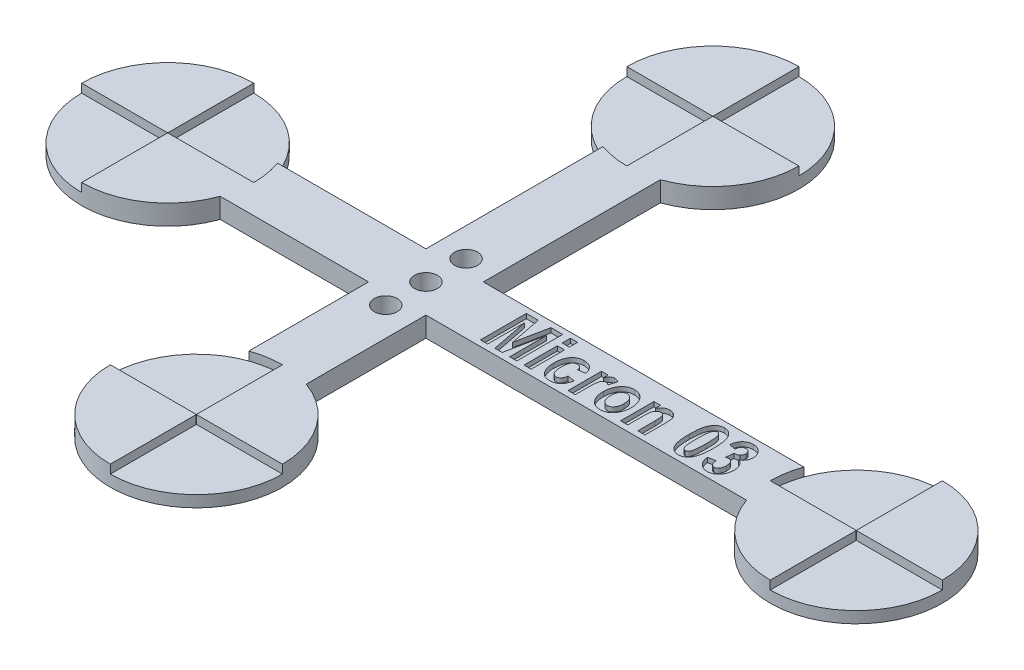
from build123d import *

# Parameters (mm, degrees)
BOSS_EXTRUDE1_DEPTH = 3.5
CUT_EXTRUDE1_DEPTH  = 1.5
SKETCH3_W           = 1.246753247
SKETCH3_H           = 1.454545455
SKETCH3_H_2         = 5.818181818
CUT_EXTRUDE2_DEPTH  = 0.8
SKETCH4_R           = 2
CUT_EXTRUDE3_DEPTH  = 4.5


with BuildPart() as part:
    # Sketch1 → Boss-Extrude1 (new body)
    with BuildSketch(Plane(origin=(0, 0, 0), x_dir=(1, 0, 0), z_dir=(0, 1, 0))):
        with BuildLine():
            Line((40, 35.857864376), (40, 5))
            Line((40, 5), (14.142135624, 5))
            ThreePointArc((14.142135624, 5), (-15, 0), (14.142135624, -5))
            Line((14.142135624, -5), (40, -5))
            Line((40, -5), (40, -25.857864376))
            ThreePointArc((40, -25.857864376), (45, -55), (50, -25.857864376))
            Line((50, -25.857864376), (50, -5))
            Line((50, -5), (105.857864376, -5))
            ThreePointArc((105.857864376, -5), (135, 0), (105.857864376, 5))
            Line((105.857864376, 5), (50, 5))
            Line((50, 5), (50, 35.857864376))
            ThreePointArc((50, 35.857864376), (45, 65), (40, 35.857864376))
        make_face()
    extrude(amount=BOSS_EXTRUDE1_DEPTH)

    # Sketch2 → Cut-Extrude1 (cut)
    with BuildSketch(Plane(origin=(0, 3.5, 0), x_dir=(1, 0, 0), z_dir=(0, 1, 0))):
        with BuildLine():
            Line((-15, 0), (-0.05, 0))
            ThreePointArc((-0.05, 0), (-0.035355339, 0.035355339), (0, 0.05))
            Line((0, 0.05), (0, 15))
            ThreePointArc((0, 15), (10.606601718, 10.606601718), (15, 0))
            Line((15, 0), (0.05, 0))
            ThreePointArc((0.05, 0), (0.035355339, -0.035355339), (0, -0.05))
            Line((0, -0.05), (0, -15))
            ThreePointArc((0, -15), (-10.606601718, -10.606601718), (-15, 0))
        make_face()
        with BuildLine():
            Line((45, 65), (45, 50.05))
            ThreePointArc((45, 50.05), (44.964644661, 50.035355339), (44.95, 50))
            Line((44.95, 50), (30, 50))
            ThreePointArc((30, 50), (34.393398282, 39.393398282), (45, 35))
            Line((45, 35), (45, 49.95))
            ThreePointArc((45, 49.95), (45.035355339, 49.964644661), (45.05, 50))
            Line((45.05, 50), (60, 50))
            ThreePointArc((60, 50), (55.606601718, 60.606601718), (45, 65))
        make_face()
        with BuildLine():
            Line((120, 15), (120, 0.05))
            ThreePointArc((120, 0.05), (120.035355339, 0.035355339), (120.05, 0))
            Line((120.05, 0), (135, 0))
            ThreePointArc((135, 0), (130.606601718, -10.606601718), (120, -15))
            Line((120, -15), (120, -0.05))
            ThreePointArc((120, -0.05), (119.964644661, -0.035355339), (119.95, 0))
            Line((119.95, 0), (105, 0))
            ThreePointArc((105, 0), (109.393398282, 10.606601718), (120, 15))
        make_face()
        with BuildLine():
            Line((30, -40), (44.95, -40))
            ThreePointArc((44.95, -40), (44.964644661, -40.035355339), (45, -40.05))
            Line((45, -40.05), (45, -55))
            ThreePointArc((45, -55), (55.606601718, -50.606601718), (60, -40))
            Line((60, -40), (45.05, -40))
            ThreePointArc((45.05, -40), (45.035355339, -39.964644661), (45, -39.95))
            Line((45, -39.95), (45, -25))
            ThreePointArc((45, -25), (34.393398282, -29.393398282), (30, -40))
        make_face()
    extrude(amount=-CUT_EXTRUDE1_DEPTH, mode=Mode.SUBTRACT)

    # Sketch3 → Cut-Extrude2 (cut)
    with BuildSketch(Plane(origin=(0, 3.5, 0), x_dir=(1, 0, 0), z_dir=(0, 1, 0))):
        Polygon((58.50036076, -4), (58.50036076, 4), (60.563672448, 4), (61.669191928, -1.561688312), (62.795815305, 4), (64.838023097, 4), (64.838023097, -4), (63.59126985, -4), (63.59126985, 2.400974026), (62.290945175, -4), (61.023088032, -4), (59.747114006, 2.400974026), (59.747114006, -4), align=None)
        with Locations((66.708152968, 3.376623377)):
            Rectangle(SKETCH3_W, SKETCH3_H)
        with Locations((66.708152968, -1.090909091)):
            Rectangle(SKETCH3_W, SKETCH3_H_2)
        with BuildLine():
            Line((72.734126993, 0.155844156), (71.487373747, -0.051948052))
            add(Edge.make_bspline(
                [(71.487373747, -0.051948052), (71.475238631, 0.013492139), (71.452160271, 0.137945199), (71.389179941, 0.307989308), (71.312160634, 0.454611766), (71.213055442, 0.573886506), (71.095416345, 0.667213464), (70.958609537, 0.733166985), (70.803936467, 0.772456922), (70.694860886, 0.776912369), (70.638347773, 0.779220779)],
                knots=[0, 0, 0, 0, 0.000199325, 0.000379073, 0.0005418, 0.000693948, 0.000840745, 0.000988855, 0.001146348, 0.001315678, 0.001315678, 0.001315678, 0.001315678], degree=3))
            add(Edge.make_bspline(
                [(70.638347773, 0.779220779), (70.600905429, 0.778062939), (70.527122523, 0.775781331), (70.420010496, 0.755102855), (70.317553938, 0.725549098), (70.222958212, 0.677663569), (70.130758823, 0.622007918), (70.046957124, 0.549315551), (69.968136169, 0.465515202), (69.894709448, 0.369037743), (69.827095322, 0.257785931), (69.770603047, 0.128257783), (69.725083376, -0.018687378), (69.68335517, -0.181979253), (69.653655963, -0.363419746), (69.633180941, -0.562384664), (69.620101663, -0.77850796), (69.618220871, -0.928551854), (69.617243876, -1.006493506)],
                knots=[0, 0, 0, 0, 0.000112201, 0.0002211, 0.00032637, 0.000430923, 0.000538128, 0.000648708, 0.000762403, 0.000882861, 0.001011764, 0.001152033, 0.001305535, 0.001472868, 0.001657284, 0.001856457, 0.002072757, 0.002306574, 0.002306574, 0.002306574, 0.002306574], degree=3))
            add(Edge.make_bspline(
                [(69.617243876, -1.006493506), (69.618261217, -1.092546265), (69.620213954, -1.257720471), (69.632711779, -1.496116795), (69.65538517, -1.714396148), (69.685469478, -1.914085761), (69.725675307, -2.093641007), (69.774055334, -2.254680712), (69.831596703, -2.395907747), (69.899086485, -2.518208897), (69.974173657, -2.623094471), (70.056196277, -2.712538943), (70.142228328, -2.791034021), (70.2374127, -2.851962864), (70.336627186, -2.901864568), (70.442857496, -2.935934853), (70.55464497, -2.95784839), (70.631749283, -2.959966029), (70.670815305, -2.961038961)],
                knots=[0, 0, 0, 0, 0.000258163, 0.000495531, 0.000715862, 0.000916302, 0.00110101, 0.001267389, 0.001420236, 0.001557572, 0.001685521, 0.001806187, 0.001921184, 0.002033748, 0.002144102, 0.002253448, 0.002367432, 0.002484495, 0.002484495, 0.002484495, 0.002484495], degree=3))
            add(Edge.make_bspline(
                [(70.670815305, -2.961038961), (70.72855094, -2.958115137), (70.840148837, -2.952463643), (70.998917272, -2.902884688), (71.141871425, -2.82385793), (71.244914469, -2.730611667), (71.318466989, -2.639969699), (71.370108431, -2.557981246), (71.418545215, -2.464077917), (71.462084604, -2.358060987), (71.501266248, -2.240396767), (71.534349316, -2.110465037), (71.565645908, -1.968673701), (71.582502685, -1.869672225), (71.59126985, -1.818181818)],
                knots=[0, 0, 0, 0, 0.000172842, 0.000334088, 0.000493972, 0.000659525, 0.000747247, 0.000843616, 0.000949622, 0.001063883, 0.001187088, 0.001321358, 0.001465921, 0.001622591, 0.001622591, 0.001622591, 0.001622591], degree=3))
            Line((71.59126985, -1.818181818), (72.838023097, -2.025974026))
            add(Edge.make_bspline(
                [(72.838023097, -2.025974026), (72.821015846, -2.110033143), (72.787894315, -2.273737832), (72.725282574, -2.51019173), (72.648292222, -2.729306841), (72.562922764, -2.933353422), (72.465367894, -3.120817392), (72.35648555, -3.292169834), (72.236010198, -3.447294215), (72.103969601, -3.586117196), (71.960430352, -3.708703947), (71.805564143, -3.814231607), (71.640086257, -3.904896068), (71.462835354, -3.977226655), (71.274845438, -4.034537616), (71.075882267, -4.074640125), (70.865713047, -4.099528833), (70.721752457, -4.102417816), (70.648088032, -4.103896104)],
                knots=[0, 0, 0, 0, 0.000257263, 0.000501018, 0.000733076, 0.000953485, 0.001164055, 0.001366255, 0.001561742, 0.001752349, 0.001940051, 0.002126916, 0.002313611, 0.002505046, 0.002700189, 0.002902356, 0.003113183, 0.003334111, 0.003334111, 0.003334111, 0.003334111], degree=3))
            add(Edge.make_bspline(
                [(70.648088032, -4.103896104), (70.554819841, -4.101887492), (70.37321271, -4.097976423), (70.110471697, -4.053593587), (69.864673186, -3.987367001), (69.639207309, -3.888476021), (69.431834059, -3.764176577), (69.243759839, -3.611361294), (69.073517705, -3.431602628), (68.925921273, -3.224317401), (68.795814013, -2.999463478), (68.681997355, -2.762165056), (68.585965745, -2.513438303), (68.506034653, -2.254410985), (68.446476255, -1.98270864), (68.403410095, -1.700737492), (68.374039392, -1.407542533), (68.371686907, -1.208406699), (68.37049063, -1.107142857)],
                knots=[0, 0, 0, 0, 0.000279523, 0.000544272, 0.000797144, 0.001041429, 0.001280302, 0.001520398, 0.001766145, 0.002020725, 0.002281892, 0.002544739, 0.002809429, 0.003081077, 0.00335717, 0.003643018, 0.003936526, 0.004240206, 0.004240206, 0.004240206, 0.004240206], degree=3))
            add(Edge.make_bspline(
                [(68.37049063, -1.107142857), (68.372239743, -0.987488549), (68.375640625, -0.75483916), (68.405336818, -0.417027711), (68.452726945, -0.100401237), (68.522926455, 0.193547978), (68.609847208, 0.466113039), (68.716501303, 0.716580192), (68.846096582, 0.943069469), (68.991820845, 1.149170928), (69.156114523, 1.330213011), (69.331961705, 1.489088097), (69.520060194, 1.623763244), (69.721234776, 1.733258723), (69.935011157, 1.818073271), (70.160732658, 1.877319248), (70.397782122, 1.916873853), (70.560259998, 1.920318934), (70.643217902, 1.922077922)],
                knots=[0, 0, 0, 0, 0.000358898, 0.000697823, 0.001016501, 0.00131851, 0.001603435, 0.001873935, 0.002133483, 0.002384849, 0.002629678, 0.002865336, 0.003094623, 0.003322001, 0.003550805, 0.003782743, 0.004021075, 0.004269712, 0.004269712, 0.004269712, 0.004269712], degree=3))
            add(Edge.make_bspline(
                [(70.643217902, 1.922077922), (70.71035858, 1.920846466), (70.841687336, 1.918437708), (71.034520622, 1.899106266), (71.217142954, 1.864581364), (71.391368457, 1.819675788), (71.554972261, 1.759740953), (71.709026878, 1.685791916), (71.853826329, 1.599814288), (71.98980103, 1.500415487), (72.115185036, 1.385394066), (72.233134509, 1.256930605), (72.340019014, 1.110862201), (72.439342218, 0.950708523), (72.526615855, 0.773374249), (72.606095879, 0.582082787), (72.676087051, 0.374743093), (72.714406275, 0.230221286), (72.734126993, 0.155844156)],
                knots=[0, 0, 0, 0, 0.000201403, 0.00039395, 0.000580532, 0.000758512, 0.000933129, 0.001102311, 0.00127047, 0.001437685, 0.001606618, 0.001780137, 0.00196001, 0.002148783, 0.002344802, 0.00255222, 0.002769885, 0.003000685, 0.003000685, 0.003000685, 0.003000685], degree=3))
        make_face()
        with BuildLine():
            Line((75.019841279, -4), (73.773088032, -4))
            Line((73.773088032, -4), (73.773088032, 1.818181818))
            Line((73.773088032, 1.818181818), (74.915945175, 1.818181818))
            Line((74.915945175, 1.818181818), (74.915945175, 0.991883117))
            add(Edge.make_bspline(
                [(74.915945175, 0.991883117), (74.940159399, 1.037952881), (74.986797897, 1.126686869), (75.05617644, 1.253336089), (75.123683954, 1.367923953), (75.192594719, 1.467096929), (75.254997633, 1.556811947), (75.319023898, 1.631359029), (75.379881779, 1.694731582), (75.457465413, 1.762170073), (75.560087337, 1.826053482), (75.691232303, 1.882473547), (75.832643067, 1.915363311), (75.929848968, 1.919815142), (75.979256863, 1.922077922)],
                knots=[0, 0, 0, 0, 0.000156131, 0.000300721, 0.000433243, 0.000554812, 0.000662946, 0.000760848, 0.000849244, 0.000926367, 0.001068679, 0.001209792, 0.001353128, 0.001501291, 0.001501291, 0.001501291, 0.001501291], degree=3))
            add(Edge.make_bspline(
                [(75.979256863, 1.922077922), (76.049468143, 1.91886318), (76.189930484, 1.912431875), (76.396264458, 1.852623193), (76.598585759, 1.762131289), (76.72239596, 1.675863479), (76.786075045, 1.631493506)],
                knots=[0, 0, 0, 0, 0.000210176, 0.00042047, 0.000639866, 0.000872208, 0.000872208, 0.000872208, 0.000872208], degree=3))
            Line((76.786075045, 1.631493506), (76.391594526, 0.319805195))
            add(Edge.make_bspline(
                [(76.391594526, 0.319805195), (76.343457298, 0.358255441), (76.252471756, 0.430931343), (76.106176233, 0.509110372), (75.96429064, 0.560954838), (75.869258342, 0.568020125), (75.823412708, 0.571428571)],
                knots=[0, 0, 0, 0, 0.000184416, 0.00034857, 0.000495904, 0.00063323, 0.00063323, 0.00063323, 0.00063323], degree=3))
            add(Edge.make_bspline(
                [(75.823412708, 0.571428571), (75.782505012, 0.569577552), (75.701066257, 0.565892554), (75.584319511, 0.525699903), (75.474380215, 0.46484784), (75.373247856, 0.375884101), (75.28120342, 0.255501948), (75.208770468, 0.094601523), (75.146148418, -0.102439271), (75.107437305, -0.295455124), (75.083085691, -0.477538767), (75.06505598, -0.645297865), (75.050951083, -0.839680763), (75.040281294, -1.060551746), (75.030100881, -1.307830134), (75.023930168, -1.582222395), (75.021131213, -1.883652001), (75.020282911, -2.093614232), (75.019841279, -2.202922078)],
                knots=[0, 0, 0, 0, 0.000122282, 0.000243439, 0.00036627, 0.000497452, 0.000644536, 0.000817347, 0.001023727, 0.001264102, 0.001406673, 0.001574831, 0.001770184, 0.001991255, 0.002238201, 0.002512628, 0.002814594, 0.00314252, 0.00314252, 0.00314252, 0.00314252], degree=3))
            Line((75.019841279, -2.202922078), (75.019841279, -4))
        make_face()
        with BuildLine():
            add(Edge.make_bspline(
                [(76.993867253, -1.00974026), (76.99773938, -0.871492577), (77.005358765, -0.599455473), (77.07087566, -0.202105645), (77.173904845, 0.177168447), (77.298261932, 0.475142281), (77.414852128, 0.700213025), (77.508933594, 0.858166819), (77.610211845, 1.0047968), (77.716400181, 1.140905493), (77.830224235, 1.265802708), (77.948905998, 1.380456268), (78.075551332, 1.483975824), (78.251872281, 1.606243165), (78.48640792, 1.734106031), (78.786697572, 1.843482079), (79.103960535, 1.910979968), (79.321452502, 1.918333961), (79.432178941, 1.922077922)],
                knots=[0, 0, 0, 0, 0.000414499, 0.00081563, 0.001204757, 0.001591247, 0.00178148, 0.00196495, 0.002142367, 0.002315787, 0.002482426, 0.002648908, 0.002810415, 0.002972534, 0.003292157, 0.00360852, 0.00392849, 0.004260331, 0.004260331, 0.004260331, 0.004260331], degree=3))
            add(Edge.make_bspline(
                [(79.432178941, 1.922077922), (79.524844362, 1.919080026), (79.706214487, 1.913212371), (79.970819979, 1.872921067), (80.219608224, 1.802229151), (80.453953528, 1.705294578), (80.670723745, 1.576365199), (80.874437856, 1.423442467), (81.059923504, 1.239208288), (81.228428557, 1.030627633), (81.37997441, 0.803981072), (81.513296238, 0.565748818), (81.625008798, 0.317712454), (81.719657136, 0.061815795), (81.787549524, -0.205805812), (81.840332848, -0.481537671), (81.871889339, -0.767122546), (81.87526987, -0.960420315), (81.876984136, -1.058441558)],
                knots=[0, 0, 0, 0, 0.000277982, 0.000544082, 0.000800519, 0.001052268, 0.001302568, 0.001555169, 0.001814604, 0.002084622, 0.002358372, 0.002631625, 0.002902613, 0.00317376, 0.003448993, 0.003729814, 0.004015574, 0.004309567, 0.004309567, 0.004309567, 0.004309567], degree=3))
            add(Edge.make_bspline(
                [(81.876984136, -1.058441558), (81.876227692, -1.131529258), (81.874729677, -1.276267575), (81.857345801, -1.490737935), (81.832372892, -1.700083082), (81.794451847, -1.904353031), (81.74632035, -2.102762528), (81.686787225, -2.295895078), (81.619804227, -2.484139081), (81.53955722, -2.665021822), (81.453170655, -2.838694854), (81.356567034, -3.000287959), (81.256676902, -3.152976813), (81.14667086, -3.291813358), (81.033747016, -3.423233057), (80.911462009, -3.541439921), (80.783056626, -3.649149424), (80.604551972, -3.775655653), (80.369934842, -3.906802618), (80.071483883, -4.020332864), (79.759616253, -4.091116904), (79.546182896, -4.0996153), (79.438672448, -4.103896104)],
                knots=[0, 0, 0, 0, 0.00021921, 0.00043411, 0.00064513, 0.000851458, 0.001056987, 0.001257262, 0.001457537, 0.001655994, 0.001850563, 0.002039049, 0.002220497, 0.002397475, 0.002570043, 0.002739947, 0.002907061, 0.003072374, 0.003395769, 0.003710226, 0.004027699, 0.00434993, 0.00434993, 0.00434993, 0.00434993], degree=3))
            add(Edge.make_bspline(
                [(79.438672448, -4.103896104), (79.352502729, -4.101341217), (79.183124459, -4.096319241), (78.934716636, -4.058456248), (78.698054839, -3.99479852), (78.472549003, -3.90676201), (78.258016744, -3.793542556), (78.054181778, -3.655526311), (77.864029071, -3.488983811), (77.683779026, -3.302138577), (77.520670531, -3.090331966), (77.380150134, -2.855461331), (77.258457363, -2.600481865), (77.162310721, -2.322961565), (77.085543251, -2.024985427), (77.033233234, -1.70496049), (77.000302919, -1.364326972), (76.996049016, -1.12994916), (76.993867253, -1.00974026)],
                knots=[0, 0, 0, 0, 0.000258443, 0.000508006, 0.000751761, 0.000992327, 0.001232686, 0.001478079, 0.001728994, 0.001989631, 0.002255885, 0.002529003, 0.002809298, 0.003101956, 0.003408675, 0.003731336, 0.004073787, 0.004434356, 0.004434356, 0.004434356, 0.004434356], degree=3))
        make_face()
        with BuildLine():
            add(Edge.make_bspline(
                [(78.2406205, -1.090909091), (78.241193573, -1.161301131), (78.242306492, -1.298003716), (78.261234707, -1.496347271), (78.288602558, -1.681695553), (78.324236438, -1.854514739), (78.376162408, -2.012893615), (78.434745234, -2.159458772), (78.506897923, -2.292206203), (78.589461187, -2.410648066), (78.680939517, -2.51464094), (78.776964817, -2.605361366), (78.875632321, -2.685555047), (78.982414792, -2.746314388), (79.091993225, -2.7960892), (79.205812587, -2.83181335), (79.324708332, -2.854023891), (79.405564639, -2.856089635), (79.446789331, -2.857142857)],
                knots=[0, 0, 0, 0, 0.000211095, 0.000409951, 0.000597062, 0.000773144, 0.000938458, 0.001096426, 0.001246068, 0.00139063, 0.001528684, 0.001660738, 0.001786746, 0.001908974, 0.002028146, 0.002147262, 0.002266036, 0.002389583, 0.002389583, 0.002389583, 0.002389583], degree=3))
            add(Edge.make_bspline(
                [(79.446789331, -2.857142857), (79.486930477, -2.856062286), (79.566168615, -2.853929251), (79.682924616, -2.831796204), (79.794636913, -2.796265769), (79.902095046, -2.746661195), (80.004819397, -2.682536946), (80.103605063, -2.604942025), (80.196824143, -2.512150646), (80.285902055, -2.407554507), (80.367452538, -2.288190002), (80.439332996, -2.15529938), (80.496230932, -2.007207398), (80.548090785, -1.84851973), (80.583928744, -1.674677795), (80.611733592, -1.488309881), (80.627963108, -1.288165559), (80.629460002, -1.150461681), (80.630230889, -1.079545455)],
                knots=[0, 0, 0, 0, 0.000120305, 0.000237481, 0.00035505, 0.000471266, 0.000591549, 0.000717557, 0.000847275, 0.000985501, 0.00112914, 0.00128021, 0.001437568, 0.001604429, 0.001780511, 0.001969228, 0.002169562, 0.00238228, 0.00238228, 0.00238228, 0.00238228], degree=3))
            add(Edge.make_bspline(
                [(80.630230889, -1.079545455), (80.629657673, -1.010234819), (80.628544962, -0.875690947), (80.609642621, -0.680588811), (80.582133444, -0.497953131), (80.546465486, -0.327351399), (80.49521573, -0.170068224), (80.433692654, -0.025632812), (80.362554163, 0.1072581), (80.279265313, 0.225728002), (80.188791642, 0.330494971), (80.093903874, 0.422586459), (79.99490702, 0.50126615), (79.890651683, 0.564846212), (79.782053107, 0.614109415), (79.669460084, 0.65026489), (79.551531628, 0.672061169), (79.471231571, 0.67422738), (79.430555565, 0.675324675)],
                knots=[0, 0, 0, 0, 0.000207849, 0.000403471, 0.000587372, 0.000761868, 0.000925636, 0.001082735, 0.001232376, 0.001376939, 0.001516219, 0.001647099, 0.001773107, 0.001894774, 0.002012466, 0.002130035, 0.002248808, 0.002370734, 0.002370734, 0.002370734, 0.002370734], degree=3))
            add(Edge.make_bspline(
                [(79.430555565, 0.675324675), (79.390416835, 0.674238638), (79.311183466, 0.672094813), (79.194392368, 0.650041164), (79.082343389, 0.614060182), (78.973968514, 0.565297339), (78.870848855, 0.500737434), (78.772125734, 0.422584114), (78.677081903, 0.331022603), (78.588667404, 0.225050714), (78.504100416, 0.107532851), (78.436606876, -0.027537366), (78.372844625, -0.171655992), (78.32568136, -0.331268167), (78.285792867, -0.502358852), (78.261951191, -0.687847561), (78.242143614, -0.884859588), (78.241136929, -1.021045607), (78.2406205, -1.090909091)],
                knots=[0, 0, 0, 0, 0.000120305, 0.000237481, 0.00035505, 0.000472742, 0.000593025, 0.000719033, 0.000849914, 0.000988139, 0.001132702, 0.001283011, 0.00144011, 0.001604937, 0.00178137, 0.001966642, 0.002165497, 0.002374969, 0.002374969, 0.002374969, 0.002374969], degree=3))
        make_face(mode=Mode.SUBTRACT)
        with BuildLine():
            Line((87.175685435, -4), (85.928932188, -4))
            Line((85.928932188, -4), (85.928932188, -1.025974026))
            add(Edge.make_bspline(
                [(85.928932188, -1.025974026), (85.92854282, -0.954543529), (85.927799442, -0.818169062), (85.924356954, -0.622819841), (85.920247564, -0.445806445), (85.911867341, -0.287253276), (85.902241106, -0.147618119), (85.891650159, -0.026736408), (85.87710847, 0.075056785), (85.856368171, 0.184335425), (85.821004006, 0.301543782), (85.764596313, 0.426141455), (85.692774231, 0.534382367), (85.604019629, 0.62160385), (85.506619056, 0.69206755), (85.401915582, 0.743240838), (85.289966246, 0.77397023), (85.213215912, 0.777447079), (85.174062058, 0.779220779)],
                knots=[0, 0, 0, 0, 0.000214292, 0.000409124, 0.000586139, 0.000745437, 0.000885387, 0.001006053, 0.001109364, 0.001193733, 0.001339584, 0.001475415, 0.001602837, 0.00172681, 0.001846644, 0.001962086, 0.002074709, 0.002191998, 0.002191998, 0.002191998, 0.002191998], degree=3))
            add(Edge.make_bspline(
                [(85.174062058, 0.779220779), (85.123447016, 0.776869331), (85.023371597, 0.772220076), (84.878191919, 0.730407315), (84.739286208, 0.667322233), (84.612395844, 0.575023409), (84.495650377, 0.46328544), (84.398737064, 0.328262501), (84.317469986, 0.175298829), (84.268630692, 0.030618942), (84.236032455, -0.101357957), (84.218310317, -0.222713773), (84.199402097, -0.363228665), (84.188161741, -0.524290952), (84.175994029, -0.704955422), (84.168471275, -0.905793407), (84.163505023, -1.126597226), (84.162974738, -1.280299629), (84.162698422, -1.36038961)],
                knots=[0, 0, 0, 0, 0.000151532, 0.000299606, 0.000449951, 0.00060715, 0.000767873, 0.000932819, 0.001103467, 0.001285727, 0.00138928, 0.001510979, 0.001653337, 0.001814575, 0.001995128, 0.00219659, 0.002417423, 0.002657688, 0.002657688, 0.002657688, 0.002657688], degree=3))
            Line((84.162698422, -1.36038961), (84.162698422, -4))
            Line((84.162698422, -4), (82.915945175, -4))
            Line((82.915945175, -4), (82.915945175, 1.818181818))
            Line((82.915945175, 1.818181818), (84.058802318, 1.818181818))
            Line((84.058802318, 1.818181818), (84.058802318, 0.965909091))
            add(Edge.make_bspline(
                [(84.058802318, 0.965909091), (84.109710936, 1.041759386), (84.208544913, 1.189015129), (84.378208436, 1.383777654), (84.556148861, 1.549983921), (84.743871586, 1.687067674), (84.943914365, 1.791672469), (85.153616398, 1.866743358), (85.373756253, 1.914536504), (85.524465529, 1.919537791), (85.60101011, 1.922077922)],
                knots=[0, 0, 0, 0, 0.000273831, 0.000531616, 0.00077285, 0.001003084, 0.001226733, 0.001447536, 0.001669767, 0.001899129, 0.001899129, 0.001899129, 0.001899129], degree=3))
            add(Edge.make_bspline(
                [(85.60101011, 1.922077922), (85.688429859, 1.918919658), (85.857463892, 1.912812868), (86.100755155, 1.857826735), (86.32221213, 1.766788484), (86.519497148, 1.639484009), (86.693501252, 1.488180451), (86.837925118, 1.311212589), (86.955005756, 1.115344188), (87.024073318, 0.933951844), (87.069245622, 0.777526046), (87.097815568, 0.646198938), (87.122467785, 0.502145243), (87.140849457, 0.345447453), (87.157608055, 0.176651439), (87.168642166, -0.004744055), (87.17517168, -0.198542646), (87.175511007, -0.332245522), (87.175685435, -0.400974026)],
                knots=[0, 0, 0, 0, 0.000261973, 0.000506549, 0.000743812, 0.00097664, 0.00120785, 0.001432751, 0.0016591, 0.001889414, 0.002012726, 0.002147427, 0.002292345, 0.002451013, 0.002620623, 0.002801175, 0.002996089, 0.003202264, 0.003202264, 0.003202264, 0.003202264], degree=3))
            Line((87.175685435, -0.400974026), (87.175685435, -4))
        make_face()
        with BuildLine():
            add(Edge.make_bspline(
                [(93.042568552, 4), (93.120143484, 3.997148674), (93.273215628, 3.991522391), (93.496552113, 3.948267667), (93.709167709, 3.877994443), (93.909593475, 3.778303449), (94.097951861, 3.649902676), (94.274716094, 3.493575316), (94.44002471, 3.309388361), (94.594940829, 3.095688722), (94.734153575, 2.845756266), (94.853050654, 2.555093261), (94.952904602, 2.222696136), (95.034271056, 1.848605187), (95.098816614, 1.432288922), (95.142527697, 0.973709188), (95.170357365, 0.473287901), (95.173862882, 0.125581293), (95.175685435, -0.055194805)],
                knots=[0, 0, 0, 0, 0.000232602, 0.000458974, 0.000679718, 0.0009026, 0.001128179, 0.00136168, 0.001608802, 0.001869231, 0.002151946, 0.002464883, 0.002809456, 0.003191901, 0.003612528, 0.004072572, 0.004573333, 0.005115628, 0.005115628, 0.005115628, 0.005115628], degree=3))
            add(Edge.make_bspline(
                [(95.175685435, -0.055194805), (95.173858892, -0.235429027), (95.170346113, -0.582052681), (95.14257855, -1.080864069), (95.098621978, -1.538317484), (95.034600767, -1.953666632), (94.952257764, -2.327486698), (94.853811541, -2.659813141), (94.733670888, -2.949980575), (94.595090938, -3.199694145), (94.439887399, -3.412685451), (94.276378827, -3.597979093), (94.099525864, -3.753792128), (93.911527253, -3.881710441), (93.71208139, -3.98233668), (93.500748445, -4.05159659), (93.278700656, -4.095734493), (93.126655602, -4.101138343), (93.049062058, -4.103896104)],
                knots=[0, 0, 0, 0, 0.000540672, 0.001039812, 0.00149824, 0.001918867, 0.002299728, 0.002645854, 0.002957293, 0.003240007, 0.003500437, 0.003746473, 0.003979974, 0.004205554, 0.004426982, 0.004647726, 0.004870909, 0.005103511, 0.005103511, 0.005103511, 0.005103511], degree=3))
            add(Edge.make_bspline(
                [(93.049062058, -4.103896104), (92.971520172, -4.100862637), (92.818612265, -4.094880825), (92.59489671, -4.054282938), (92.382435066, -3.983452229), (92.182511086, -3.883672907), (91.993665393, -3.757214281), (91.816991446, -3.602360262), (91.651459776, -3.419950023), (91.525616278, -3.246353686), (91.430990718, -3.092878847), (91.364980322, -2.964508803), (91.303455869, -2.825479381), (91.244235797, -2.676576112), (91.19349064, -2.514885831), (91.144536647, -2.343474895), (91.100591604, -2.160968409), (91.062673394, -1.967931987), (91.02559404, -1.76477297), (90.998032431, -1.550003327), (90.97076078, -1.325090023), (90.952664467, -1.088321983), (90.93572137, -0.841612758), (90.925283351, -0.583390093), (90.915909942, -0.315001944), (90.915933294, -0.132043959), (90.915945175, -0.038961039)],
                knots=[0, 0, 0, 0, 0.000232602, 0.000458677, 0.000679421, 0.000902303, 0.001126975, 0.001359407, 0.001605326, 0.001864441, 0.002001422, 0.002145912, 0.00229706, 0.002457438, 0.002626339, 0.002805176, 0.002992203, 0.003189274, 0.003395315, 0.003611584, 0.003838724, 0.004074918, 0.004323825, 0.00458057, 0.004850172, 0.005129398, 0.005129398, 0.005129398, 0.005129398], degree=3))
            add(Edge.make_bspline(
                [(90.915945175, -0.038961039), (90.917766425, 0.140733062), (90.92126861, 0.486277146), (90.949096706, 0.983455445), (90.992786068, 1.438795514), (91.057455354, 1.852398974), (91.139031184, 2.224773358), (91.238156972, 2.556355193), (91.357927524, 2.84609395), (91.496547236, 3.095795814), (91.651741372, 3.308789888), (91.815252237, 3.494082856), (91.992104631, 3.649896058), (92.180103387, 3.777814329), (92.379549212, 3.878440579), (92.590882167, 3.947700486), (92.812929954, 3.99183839), (92.964975007, 3.997242239), (93.042568552, 4)],
                knots=[0, 0, 0, 0, 0.000539049, 0.001036568, 0.001493381, 0.0019108, 0.002291661, 0.002636234, 0.002947673, 0.003230387, 0.003490817, 0.003736853, 0.003970355, 0.004195934, 0.004417363, 0.004638106, 0.004861289, 0.005093891, 0.005093891, 0.005093891, 0.005093891], degree=3))
        make_face()
        with BuildLine():
            add(Edge.make_bspline(
                [(93.045815305, 2.753246753), (93.016983802, 2.751588419), (92.959509622, 2.748282613), (92.875927262, 2.724571332), (92.79639698, 2.686845816), (92.722427151, 2.631936572), (92.654531179, 2.560572149), (92.589331771, 2.475933398), (92.529382821, 2.37557449), (92.471821912, 2.257031527), (92.422907436, 2.108173752), (92.379831447, 1.922528032), (92.345944957, 1.69496366), (92.317590249, 1.425720345), (92.292957589, 1.115056325), (92.278036586, 0.762026881), (92.268158161, 0.367481909), (92.267133043, 0.090375275), (92.266594526, -0.055194805)],
                knots=[0, 0, 0, 0, 8.6421e-05, 0.000172276, 0.000258682, 0.000349271, 0.00044685, 0.000553351, 0.00066917, 0.000796964, 0.000947894, 0.001138079, 0.00136814, 0.001637587, 0.001950225, 0.002302871, 0.002697472, 0.003134172, 0.003134172, 0.003134172, 0.003134172], degree=3))
            add(Edge.make_bspline(
                [(92.266594526, -0.055194805), (92.267123328, -0.200765322), (92.268127989, -0.477331814), (92.278100069, -0.871330634), (92.29283468, -1.223292397), (92.317841907, -1.533920343), (92.34564763, -1.80268425), (92.37998794, -2.030198873), (92.42300039, -2.215269381), (92.471382223, -2.36384325), (92.52979398, -2.481451586), (92.589390764, -2.581371854), (92.653964499, -2.666118067), (92.722995564, -2.735808707), (92.79633331, -2.790804977), (92.875943778, -2.828451078), (92.959505472, -2.852182826), (93.016982415, -2.855485896), (93.045815305, -2.857142857)],
                knots=[0, 0, 0, 0, 0.0004367, 0.000829678, 0.001182325, 0.001493344, 0.001764405, 0.001992863, 0.002183047, 0.002333978, 0.002460309, 0.002576128, 0.002682629, 0.002779053, 0.002869643, 0.002956049, 0.003041904, 0.003128325, 0.003128325, 0.003128325, 0.003128325], degree=3))
            add(Edge.make_bspline(
                [(93.045815305, -2.857142857), (93.075188368, -2.85552029), (93.133206372, -2.852315378), (93.21738504, -2.828542533), (93.297029049, -2.790253808), (93.372435814, -2.736496976), (93.439646108, -2.664443264), (93.506337432, -2.581825172), (93.563423586, -2.480471516), (93.621525538, -2.362653873), (93.670754282, -2.213878514), (93.710709098, -2.027621166), (93.748134759, -1.800724279), (93.775757394, -1.53179805), (93.798173843, -1.221589379), (93.813727392, -0.869719468), (93.823431124, -0.476245826), (93.824483267, -0.20022291), (93.825036084, -0.055194805)],
                knots=[0, 0, 0, 0, 8.8037e-05, 0.000173892, 0.000260298, 0.000352202, 0.00044978, 0.000554999, 0.000669985, 0.000797778, 0.000948709, 0.001138526, 0.001368845, 0.001638291, 0.001949188, 0.002301835, 0.002694813, 0.00312989, 0.00312989, 0.00312989, 0.00312989], degree=3))
            add(Edge.make_bspline(
                [(93.825036084, -0.055194805), (93.824478904, 0.090374192), (93.823418258, 0.367478764), (93.813778191, 0.762037569), (93.798092676, 1.114981824), (93.775844364, 1.425743409), (93.748129467, 1.695205512), (93.710705916, 1.922098251), (93.670766677, 2.108368799), (93.621491087, 2.257107732), (93.563526869, 2.37503186), (93.505793041, 2.476420917), (93.440190416, 2.560429298), (93.372374904, 2.632553578), (93.297043894, 2.68636923), (93.217381216, 2.724643459), (93.133207354, 2.748420037), (93.075188698, 2.751624443), (93.045815305, 2.753246753)],
                knots=[0, 0, 0, 0, 0.0004367, 0.000831301, 0.001183948, 0.001496464, 0.00176591, 0.001996229, 0.002186046, 0.002336977, 0.00246477, 0.002579756, 0.002686257, 0.002783835, 0.002875739, 0.002962145, 0.003048, 0.003136037, 0.003136037, 0.003136037, 0.003136037], degree=3))
        make_face(mode=Mode.SUBTRACT)
        with BuildLine():
            Line((96.006854266, -1.922077922), (97.253607513, -1.714285714))
            add(Edge.make_bspline(
                [(97.253607513, -1.714285714), (97.262765444, -1.801759701), (97.280131434, -1.967634751), (97.338670953, -2.198135259), (97.419325256, -2.39732776), (97.524427601, -2.562700332), (97.648737479, -2.692126064), (97.783802282, -2.788428385), (97.932493501, -2.847377977), (98.036114506, -2.853883791), (98.088023097, -2.857142857)],
                knots=[0, 0, 0, 0, 0.000263578, 0.000499817, 0.000710855, 0.000905836, 0.001083794, 0.001245913, 0.001400577, 0.001555828, 0.001555828, 0.001555828, 0.001555828], degree=3))
            add(Edge.make_bspline(
                [(98.088023097, -2.857142857), (98.144453048, -2.852764076), (98.257053838, -2.84402662), (98.416500816, -2.772297819), (98.559408761, -2.656979255), (98.685163186, -2.498938662), (98.790210316, -2.302480658), (98.863660584, -2.068625203), (98.909146232, -1.802637276), (98.913602865, -1.613838803), (98.915945175, -1.51461039)],
                knots=[0, 0, 0, 0, 0.000168745, 0.000336716, 0.000514696, 0.000715496, 0.000938473, 0.001179242, 0.001447728, 0.001745165, 0.001745165, 0.001745165, 0.001745165], degree=3))
            add(Edge.make_bspline(
                [(98.915945175, -1.51461039), (98.913655979, -1.421854997), (98.909313712, -1.245911676), (98.86325432, -0.997691244), (98.78967358, -0.779779665), (98.686081909, -0.595624036), (98.561013398, -0.44736288), (98.420102961, -0.338320261), (98.262792692, -0.271839203), (98.153020804, -0.263791398), (98.097763357, -0.25974026)],
                knots=[0, 0, 0, 0, 0.000277982, 0.00052729, 0.000754215, 0.000965035, 0.001157314, 0.001332316, 0.001495406, 0.00166072, 0.00166072, 0.00166072, 0.00166072], degree=3))
            add(Edge.make_bspline(
                [(98.097763357, -0.25974026), (98.058687211, -0.260834251), (97.976668314, -0.263130484), (97.848959894, -0.28922019), (97.709618529, -0.323523317), (97.614816872, -0.357336949), (97.565295824, -0.375)],
                knots=[0, 0, 0, 0, 0.000117063, 0.00024571, 0.000389816, 0.000547418, 0.000547418, 0.000547418, 0.000547418], degree=3))
            Line((97.565295824, -0.375), (97.701659461, 0.987012987))
            add(Edge.make_bspline(
                [(97.701659461, 0.987012987), (97.783079744, 0.988171863), (97.938616631, 0.99038566), (98.15855671, 1.035004937), (98.355217207, 1.109310776), (98.463432179, 1.189501245), (98.516594526, 1.228896104)],
                knots=[0, 0, 0, 0, 0.000243772, 0.000465676, 0.000670363, 0.000868022, 0.000868022, 0.000868022, 0.000868022], degree=3))
            add(Edge.make_bspline(
                [(98.516594526, 1.228896104), (98.562507573, 1.272794169), (98.65438082, 1.360635384), (98.746234269, 1.532638769), (98.803723835, 1.727347537), (98.809191085, 1.865889417), (98.812049071, 1.938311688)],
                knots=[0, 0, 0, 0, 0.000189491, 0.000379176, 0.000576968, 0.000793614, 0.000793614, 0.000793614, 0.000793614], degree=3))
            add(Edge.make_bspline(
                [(98.812049071, 1.938311688), (98.809897811, 1.998617201), (98.805772749, 2.114253631), (98.765120582, 2.277433859), (98.695570009, 2.419982267), (98.598328475, 2.538949511), (98.481396785, 2.635378598), (98.346536008, 2.705160416), (98.195994074, 2.746781775), (98.090456129, 2.751048312), (98.036075045, 2.753246753)],
                knots=[0, 0, 0, 0, 0.000180662, 0.000346422, 0.000500334, 0.000652707, 0.000803821, 0.00095194, 0.001105141, 0.001267997, 0.001267997, 0.001267997, 0.001267997], degree=3))
            add(Edge.make_bspline(
                [(98.036075045, 2.753246753), (97.981039879, 2.750258909), (97.872500144, 2.744366317), (97.715521142, 2.692832858), (97.570974892, 2.608484797), (97.440381865, 2.491463077), (97.326406927, 2.343462011), (97.239532236, 2.161509971), (97.177291923, 1.948786284), (97.15924536, 1.795347185), (97.149711409, 1.714285714)],
                knots=[0, 0, 0, 0, 0.000164763, 0.000324943, 0.000490057, 0.000663698, 0.000847799, 0.001046727, 0.00126504, 0.001509545, 0.001509545, 0.001509545, 0.001509545], degree=3))
            Line((97.149711409, 1.714285714), (96.006854266, 1.922077922))
            add(Edge.make_bspline(
                [(96.006854266, 1.922077922), (96.023270971, 2.009925755), (96.055167657, 2.180608898), (96.116412078, 2.42596001), (96.189556759, 2.652690657), (96.27315945, 2.861059088), (96.369720115, 3.050051624), (96.474437465, 3.221839182), (96.592306693, 3.373993957), (96.720767602, 3.507948104), (96.860282178, 3.623182685), (97.00658065, 3.725375618), (97.163539979, 3.809210278), (97.32778572, 3.879907256), (97.501565056, 3.933216078), (97.683432821, 3.972340634), (97.874783144, 3.995151636), (98.005170497, 3.998360496), (98.071789331, 4)],
                knots=[0, 0, 0, 0, 0.000268069, 0.000520841, 0.000758021, 0.000982306, 0.001193576, 0.001394048, 0.001584979, 0.001769823, 0.001949616, 0.002127032, 0.00230427, 0.002482472, 0.002662696, 0.002848642, 0.003039932, 0.003239772, 0.003239772, 0.003239772, 0.003239772], degree=3))
            add(Edge.make_bspline(
                [(98.071789331, 4), (98.146017412, 3.998196042), (98.291284777, 3.994665622), (98.502973337, 3.965144099), (98.702317445, 3.915922087), (98.890943446, 3.849996226), (99.06719188, 3.761412134), (99.231489245, 3.653308449), (99.386233272, 3.528293046), (99.523301878, 3.381408392), (99.648738442, 3.226226619), (99.758340791, 3.064327157), (99.851328158, 2.898970621), (99.926472186, 2.728692558), (99.985362602, 2.554290401), (100.0271115, 2.375442243), (100.054631168, 2.1929516), (100.057407974, 2.069903984), (100.058802318, 2.008116883)],
                knots=[0, 0, 0, 0, 0.000222616, 0.000435668, 0.00063962, 0.000837818, 0.001033837, 0.001229702, 0.00142696, 0.001629043, 0.001831106, 0.002025166, 0.002214851, 0.00239946, 0.002582729, 0.00276622, 0.002949885, 0.003135127, 0.003135127, 0.003135127, 0.003135127], degree=3))
            add(Edge.make_bspline(
                [(100.058802318, 2.008116883), (100.056136353, 1.92511722), (100.050904825, 1.762243751), (100.005396143, 1.524317317), (99.932581959, 1.298628205), (99.829025399, 1.085787691), (99.696839493, 0.886033822), (99.532513199, 0.701834125), (99.343346753, 0.526259888), (99.198170585, 0.426267201), (99.123737383, 0.375)],
                knots=[0, 0, 0, 0, 0.000248806, 0.000488242, 0.000723877, 0.000958392, 0.001196121, 0.001440006, 0.001697392, 0.001968204, 0.001968204, 0.001968204, 0.001968204], degree=3))
            add(Edge.make_bspline(
                [(99.123737383, 0.375), (99.165231384, 0.36188695), (99.248325367, 0.335627359), (99.365988948, 0.279139664), (99.47915876, 0.214590355), (99.585141764, 0.137098779), (99.686143726, 0.049619301), (99.779959691, -0.049941401), (99.868758502, -0.159896234), (99.950317785, -0.280666891), (100.025739265, -0.410878008), (100.090405837, -0.549965987), (100.143401606, -0.697634052), (100.190018399, -0.851659609), (100.222641309, -1.014951118), (100.249551333, -1.18485127), (100.263840737, -1.363390631), (100.265661268, -1.484826408), (100.266594526, -1.547077922)],
                knots=[0, 0, 0, 0, 0.000130397, 0.000261126, 0.0003906, 0.000520815, 0.000654288, 0.000790931, 0.000930626, 0.001077862, 0.001227671, 0.001381644, 0.00153726, 0.001698039, 0.001863918, 0.00203634, 0.00221389, 0.002400642, 0.002400642, 0.002400642, 0.002400642], degree=3))
            add(Edge.make_bspline(
                [(100.266594526, -1.547077922), (100.265018474, -1.637553413), (100.26193217, -1.814727148), (100.229064645, -2.073961652), (100.181808195, -2.32204107), (100.111739684, -2.55863119), (100.020277144, -2.782555498), (99.911310555, -2.995793298), (99.781042901, -3.195831481), (99.631686766, -3.380899584), (99.471818654, -3.550882047), (99.29956885, -3.697699106), (99.121590319, -3.823768916), (98.933875079, -3.92549289), (98.739516534, -4.00496325), (98.537126055, -4.062633391), (98.327330004, -4.097458159), (98.184474433, -4.101736687), (98.112373747, -4.103896104)],
                knots=[0, 0, 0, 0, 0.000271279, 0.000531232, 0.000782745, 0.001028267, 0.001270036, 0.001507455, 0.001745649, 0.001984726, 0.002220116, 0.002444618, 0.002662592, 0.002873256, 0.003083676, 0.003291278, 0.00350345, 0.003719658, 0.003719658, 0.003719658, 0.003719658], degree=3))
            add(Edge.make_bspline(
                [(98.112373747, -4.103896104), (98.043559774, -4.101939992), (97.907540613, -4.0980735), (97.70798612, -4.069986649), (97.516585277, -4.0244916), (97.333059622, -3.960817512), (97.157795512, -3.878108669), (96.990983312, -3.775878571), (96.831563289, -3.657722135), (96.682375807, -3.52085829), (96.544322061, -3.368560558), (96.420765602, -3.201109593), (96.313427994, -3.019600991), (96.220827233, -2.82558491), (96.142371087, -2.618897391), (96.081651324, -2.398588353), (96.033189191, -2.165528996), (96.015773717, -2.004533062), (96.006854266, -1.922077922)],
                knots=[0, 0, 0, 0, 0.000206399, 0.000407972, 0.000603271, 0.000795796, 0.000989686, 0.001183461, 0.001381838, 0.001584077, 0.001789811, 0.00199761, 0.002207252, 0.002421451, 0.002641854, 0.002869527, 0.003106395, 0.003355069, 0.003355069, 0.003355069, 0.003355069], degree=3))
        make_face()
    extrude(amount=-CUT_EXTRUDE2_DEPTH, mode=Mode.SUBTRACT)

    # Sketch4 → Cut-Extrude3 (cut, through all)
    with BuildSketch(Plane(origin=(0, 3.5, 0), x_dir=(1, 0, 0), z_dir=(0, 1, 0))):
        with Locations((45, 0)):
            Circle(SKETCH4_R)
        with Locations((45, 7)):
            Circle(SKETCH4_R)
        with Locations((45, -7)):
            Circle(SKETCH4_R)
    extrude(amount=-CUT_EXTRUDE3_DEPTH, mode=Mode.SUBTRACT)


solid = part.part
